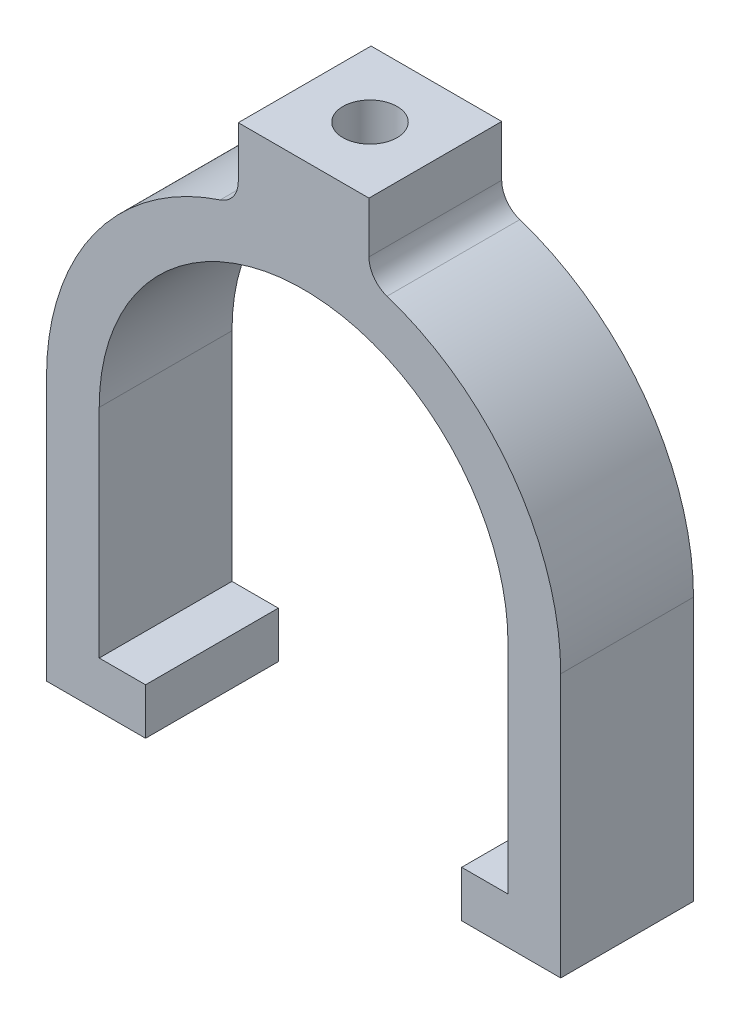
from build123d import *

# Parameters (mm, degrees)
BOSS_EXTRUDE1_DEPTH      = 16.002
FILLET1_R                = 3.175
F_5_16_18_TAPPED_HOLE1_D = 6.5278


with BuildPart() as part:
    # Sketch2 → Boss-Extrude1 (new body)
    with BuildSketch(Plane.XY):
        with BuildLine():
            Line((-24.634929355, 0), (-24.634929355, -26.162))
            Line((-24.634929355, -26.162), (-19.05, -26.162))
            Line((-19.05, -26.162), (-19.05, -31.75))
            Line((-19.05, -31.75), (-30.988, -31.75))
            Line((-30.988, -31.75), (-30.988, 0))
            ThreePointArc((-30.988, 0), (-24.5240996, 18.768520453), (-7.874, 29.576552267))
            Line((-7.874, 29.576552267), (-7.874, 38.1))
            Line((-7.874, 38.1), (7.874, 38.1))
            Line((7.874, 38.1), (7.874, 29.576552267))
            ThreePointArc((7.874, 29.576552267), (24.5240996, 18.768520453), (30.988, 0))
            Line((30.988, 0), (30.988, -31.75))
            Line((30.988, -31.75), (19.05, -31.75))
            Line((19.05, -31.75), (19.05, -26.162))
            Line((19.05, -26.162), (24.634929355, -26.162))
            Line((24.634929355, -26.162), (24.634929355, 0))
            ThreePointArc((24.634929355, 0), (0, 24.634929355), (-24.634929355, 0))
        make_face()
    extrude(amount=BOSS_EXTRUDE1_DEPTH)

    # Fillet1
    fillet1_edges = [part.edges().sort_by_distance(p)[0] for p in [
        (-7.874, 29.576552267, 8.001),
        (7.874, 29.576552267, 8.001),
    ]]
    fillet(fillet1_edges, radius=FILLET1_R)

    # 5/16-18 Tapped Hole1 (through all)
    with Locations(Plane(origin=(0, 38.1, 0), x_dir=(1, 0, 0), z_dir=(0, 1, 0))):
        with Locations((0, -8.001)):
            Hole(F_5_16_18_TAPPED_HOLE1_D / 2)


solid = part.part
